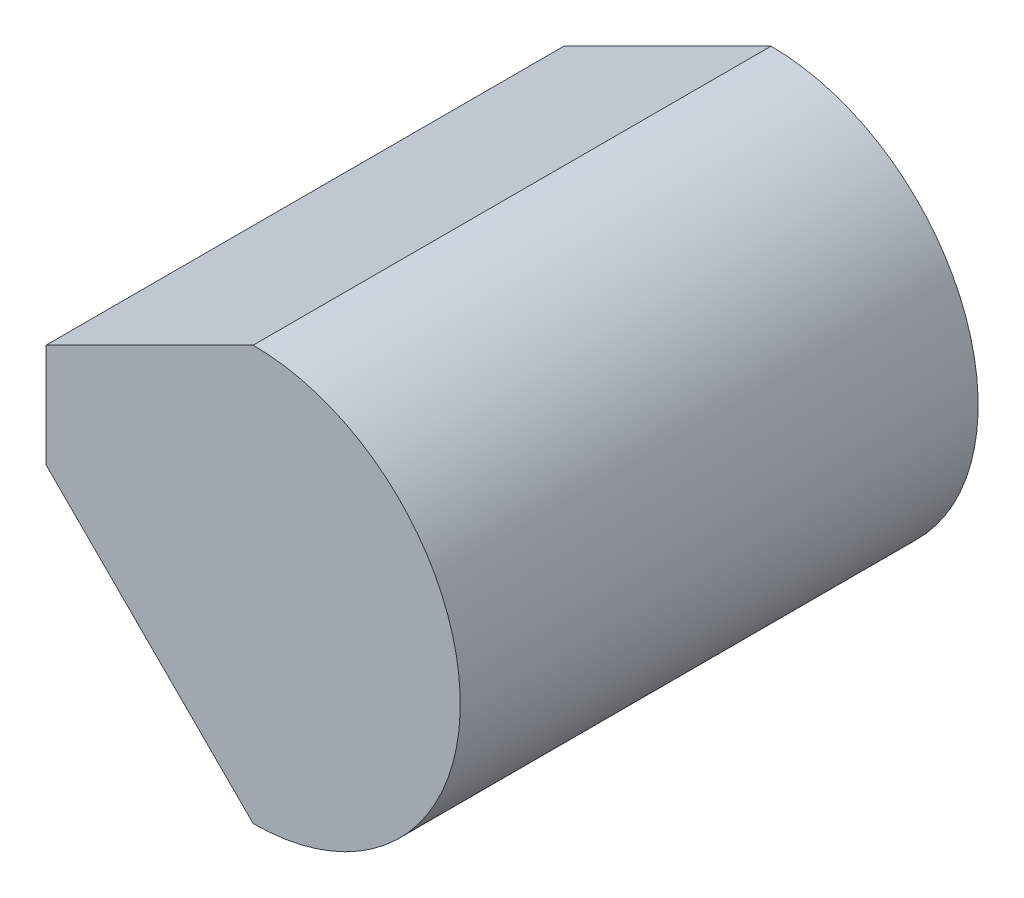
from build123d import *

# Parameters (mm, degrees)
BOSS_EXTRUDE1_DEPTH = 25


with BuildPart() as part:
    # Sketch1 → Boss-Extrude1 (new body)
    with BuildSketch(Plane.XY):
        with BuildLine():
            Line((-10, 10), (-10, 15))
            Line((-10, 15), (0, 20))
            ThreePointArc((0, 20), (10, 10), (0, 0))
            Line((0, 0), (-10, 10))
        make_face()
    extrude(amount=BOSS_EXTRUDE1_DEPTH)


solid = part.part
